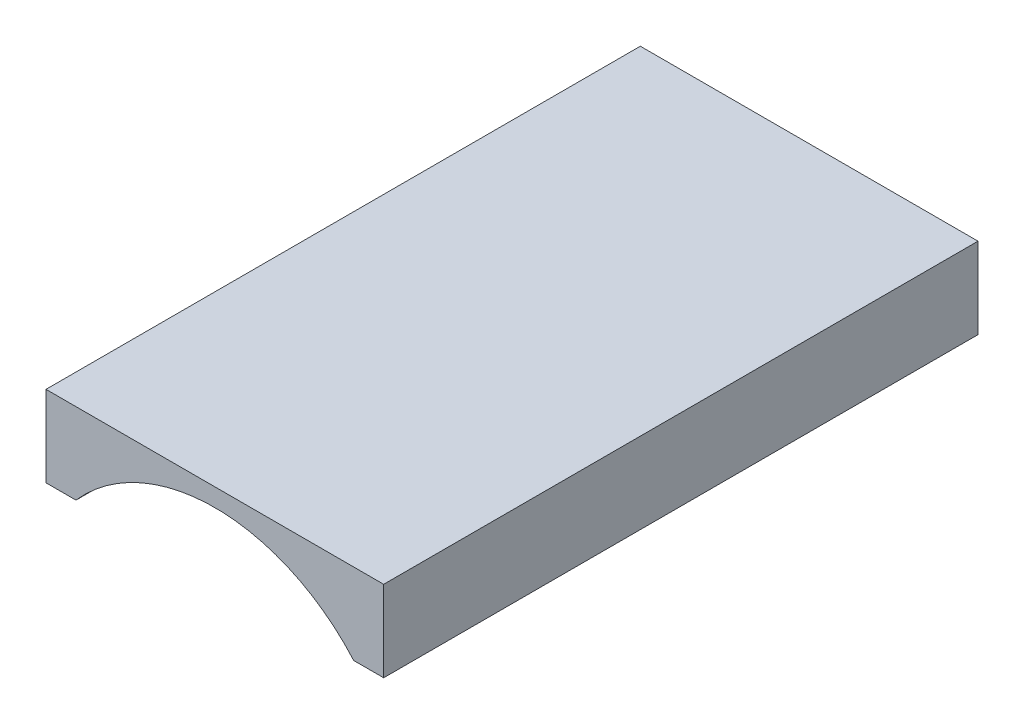
from build123d import *

# Parameters (mm, degrees)
SKETCH2_W           = 15
SKETCH2_H           = 3.597222937
BOSS_EXTRUDE1_DEPTH = 26.4
CUT_EXTRUDE1_DEPTH  = 26.4


with BuildPart() as part:
    # Sketch2 → Boss-Extrude1 (new body)
    with BuildSketch(Plane.XY):
        with Locations((50.434775134, 23.107461061)):
            Rectangle(SKETCH2_W, SKETCH2_H)
    extrude(amount=-BOSS_EXTRUDE1_DEPTH)

    # Sketch3 → Cut-Extrude1 (cut)
    with BuildSketch(Plane.XY):
        with BuildLine():
            Line((44.266306929, 21.308849592), (56.603243339, 21.308849592))
            ThreePointArc((56.603243339, 21.308849592), (50.434775134, 24.106072529), (44.266306929, 21.308849592))
        make_face()
    extrude(amount=-CUT_EXTRUDE1_DEPTH, mode=Mode.SUBTRACT)


solid = part.part
